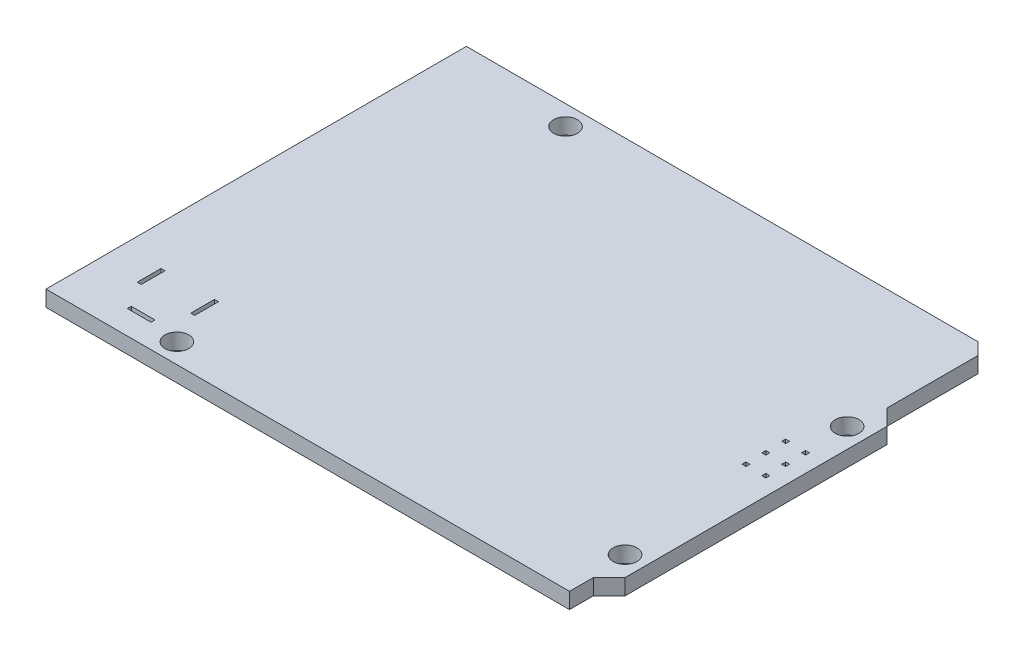
from build123d import *

# Parameters (mm, degrees)
SKETCH1_R           = 1.5
BOSS_EXTRUDE1_DEPTH = 2
SKETCH5_W           = 0.5
SKETCH5_H           = 3
SKETCH5_W_2         = 3
SKETCH5_H_2         = 0.5
CUT_EXTRUDE2_DEPTH  = 3
SKETCH6_W           = 0.5
SKETCH6_H           = 0.5
CUT_EXTRUDE3_DEPTH  = 3


with BuildPart() as part:
    # Sketch1 → Boss-Extrude1 (new body)
    with BuildSketch(Plane(origin=(0, 0, 0), x_dir=(1, 0, 0), z_dir=(0, 1, 0))):
        Polygon((0, 53), (0, 0), (66, 0), (66, 3), (68, 5), (68, 38), (66, 40), (66, 51.5), (64.5, 53), align=None)
        with Locations((15, 50.5)):
            Circle(SKETCH1_R, mode=Mode.SUBTRACT)
        with Locations((14, 2.5)):
            Circle(SKETCH1_R, mode=Mode.SUBTRACT)
        with Locations((65.5, 7.5)):
            Circle(SKETCH1_R, mode=Mode.SUBTRACT)
        with Locations((65.5, 35.5)):
            Circle(SKETCH1_R, mode=Mode.SUBTRACT)
    extrude(amount=BOSS_EXTRUDE1_DEPTH)

    # Sketch5 → Cut-Extrude2 (cut, through all)
    with BuildSketch(Plane.XZ):
        with Locations((5.25, -8)):
            Rectangle(SKETCH5_W, SKETCH5_H)
        with Locations((12, -8)):
            Rectangle(SKETCH5_W, SKETCH5_H)
        with Locations((8.75, -3.25)):
            Rectangle(SKETCH5_W_2, SKETCH5_H_2)
    extrude(amount=-CUT_EXTRUDE2_DEPTH, mode=Mode.SUBTRACT)

    # Sketch6 → Cut-Extrude3 (cut, through all)
    with BuildSketch(Plane(origin=(0, 0, 0), x_dir=(-1, 0, 0), z_dir=(0, -1, 0))):
        with Locations((-63.25, 25)):
            Rectangle(SKETCH6_W, SKETCH6_H)
        with Locations((-65.75, 25)):
            Rectangle(SKETCH6_W, SKETCH6_H)
        with Locations((-65.75, 27.5)):
            Rectangle(SKETCH6_W, SKETCH6_H)
        with Locations((-65.75, 30)):
            Rectangle(SKETCH6_W, SKETCH6_H)
        with Locations((-63.25, 30)):
            Rectangle(SKETCH6_W, SKETCH6_H)
        with Locations((-63.25, 27.5)):
            Rectangle(SKETCH6_W, SKETCH6_H)
    extrude(amount=-CUT_EXTRUDE3_DEPTH, mode=Mode.SUBTRACT)


solid = part.part
